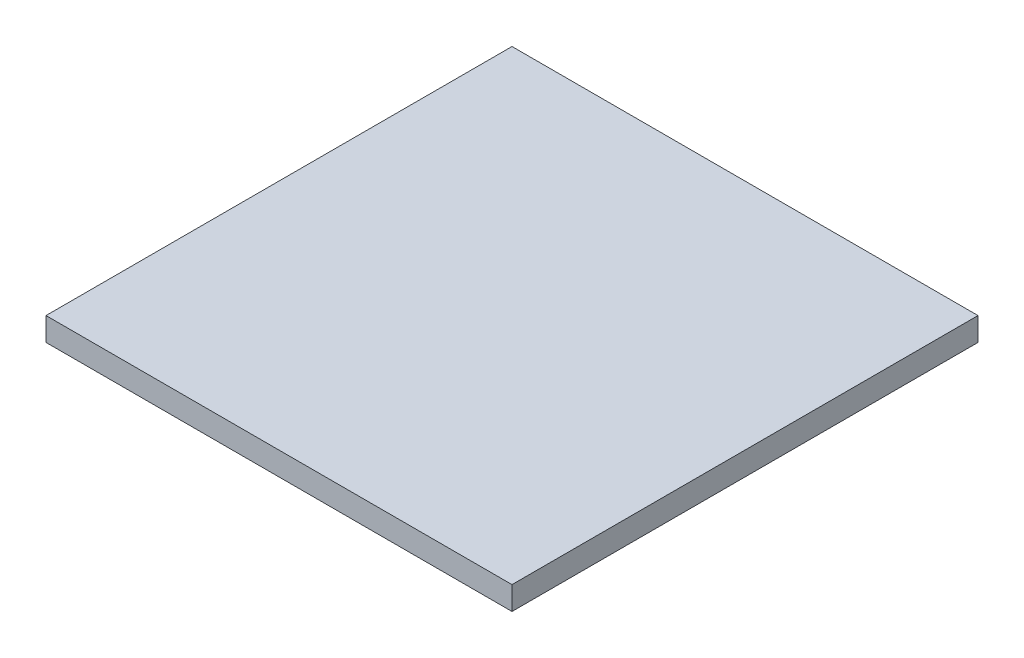
from build123d import *

# Parameters (mm, degrees)
SKETCH1_W           = 80
SKETCH1_H           = 80
BOSS_EXTRUDE1_DEPTH = 4


with BuildPart() as part:
    # Sketch1 → Boss-Extrude1 (new body)
    with BuildSketch(Plane(origin=(0, 0, 0), x_dir=(1, 0, 0), z_dir=(0, 1, 0))):
        with Locations((40, 40)):
            Rectangle(SKETCH1_W, SKETCH1_H)
    extrude(amount=BOSS_EXTRUDE1_DEPTH)


solid = part.part
